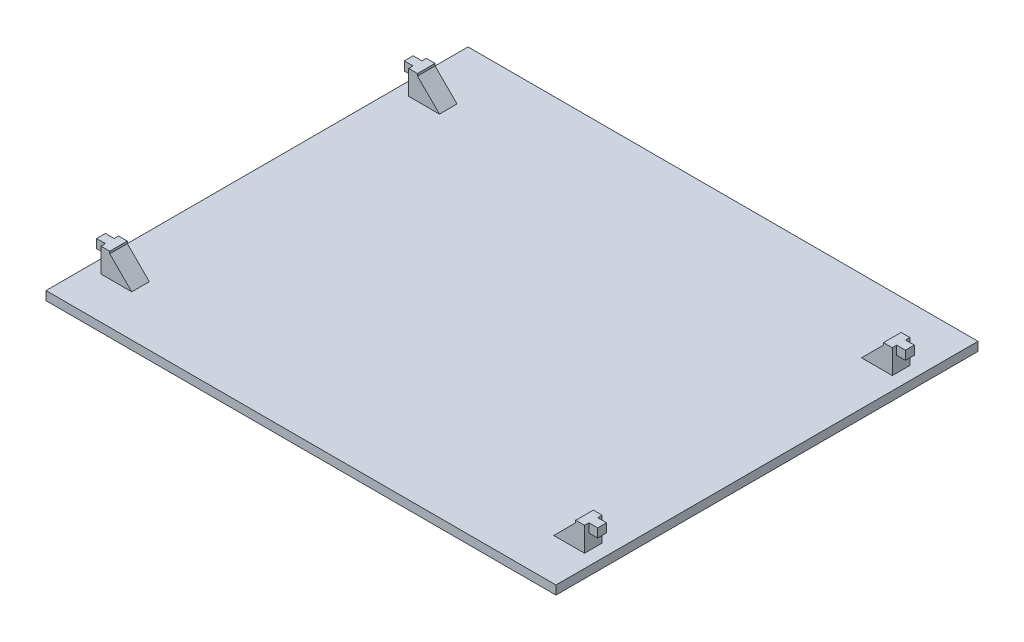
from build123d import *

# Parameters (mm, degrees)
SKETCH1_W           = 116
SKETCH1_H           = 96
BOSS_EXTRUDE1_DEPTH = 2
SKETCH2_W           = 2
SKETCH2_H           = 4
BOSS_EXTRUDE2_DEPTH = 5.5
SKETCH3_W           = 2
SKETCH3_H           = 2
BOSS_EXTRUDE3_DEPTH = 2
CHAMFER2_SIZE       = 5


with BuildPart() as part:
    # Sketch1 → Boss-Extrude1 (new body)
    with BuildSketch(Plane(origin=(0, 0, 0), x_dir=(1, 0, 0), z_dir=(0, 1, 0))):
        Rectangle(SKETCH1_W, SKETCH1_H)
    extrude(amount=BOSS_EXTRUDE1_DEPTH)

    # Sketch2 → Boss-Extrude2 (add)
    with BuildSketch(Plane(origin=(0, 2, 0), x_dir=(1, 0, 0), z_dir=(0, 1, 0))):
        with Locations((54, -36.5)):
            Rectangle(SKETCH2_W, SKETCH2_H)
        with Locations((54, 33.5)):
            Rectangle(SKETCH2_W, SKETCH2_H)
    boss_extrude2 = extrude(amount=BOSS_EXTRUDE2_DEPTH)

    # Sketch3 → Boss-Extrude3 (add)
    with BuildSketch(Plane(origin=(55, 0, 0), x_dir=(0, 0, -1), z_dir=(1, 0, 0))):
        with Locations((-36.5, 6.5)):
            Rectangle(SKETCH3_W, SKETCH3_H)
        with Locations((33.5, 6.5)):
            Rectangle(SKETCH3_W, SKETCH3_H)
    boss_extrude3 = extrude(amount=BOSS_EXTRUDE3_DEPTH)

    # Mirror1: Boss-Extrude2, Boss-Extrude3 across plane
    add(boss_extrude2.mirror(Plane(origin=(0, 0, 0), x_dir=(0, 0, 1), z_dir=(1, 0, 0))))
    add(boss_extrude3.mirror(Plane(origin=(0, 0, 0), x_dir=(0, 0, 1), z_dir=(1, 0, 0))))

    # Chamfer2
    chamfer2_edges = [part.edges().sort_by_distance(p)[0] for p in [
        (53, 2, 36.5),
        (53, 2, -33.5),
        (-53, 2, 36.5),
        (-53, 2, -33.5),
    ]]
    chamfer(chamfer2_edges, length=CHAMFER2_SIZE)


solid = part.part
